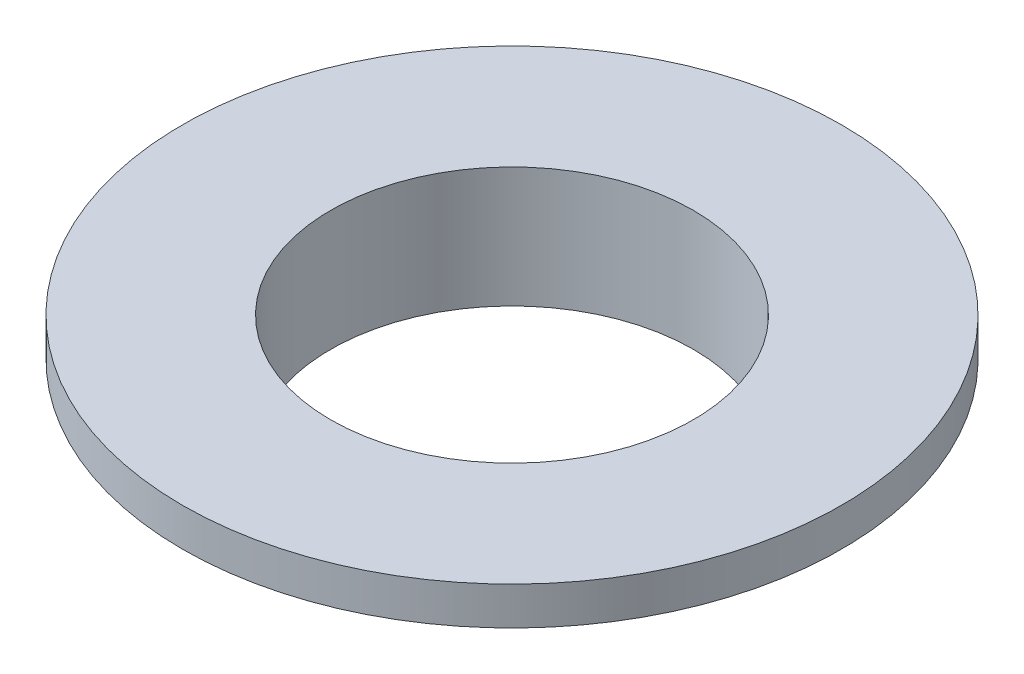
from build123d import *

# Parameters (mm, degrees)
SKETCH1_R           = 13
BOSS_EXTRUDE1_DEPTH = 1.5
SKETCH2_R           = 7.75
BOSS_EXTRUDE2_DEPTH = 3.25
SKETCH3_R           = 7.1554
CUT_EXTRUDE1_DEPTH  = 5.75


with BuildPart() as part:
    # Sketch1 → Boss-Extrude1 (new body)
    with BuildSketch(Plane(origin=(0, 0, 0), x_dir=(1, 0, 0), z_dir=(0, 1, 0))):
        Circle(SKETCH1_R)
    extrude(amount=BOSS_EXTRUDE1_DEPTH)

    # Sketch2 → Boss-Extrude2 (add)
    with BuildSketch(Plane.XZ):
        Circle(SKETCH2_R)
    extrude(amount=BOSS_EXTRUDE2_DEPTH)

    # Sketch3 → Cut-Extrude1 (cut, through all)
    with BuildSketch(Plane(origin=(0, 1.5, 0), x_dir=(1, 0, 0), z_dir=(0, 1, 0))):
        Circle(SKETCH3_R)
    extrude(amount=-CUT_EXTRUDE1_DEPTH, mode=Mode.SUBTRACT)


solid = part.part
